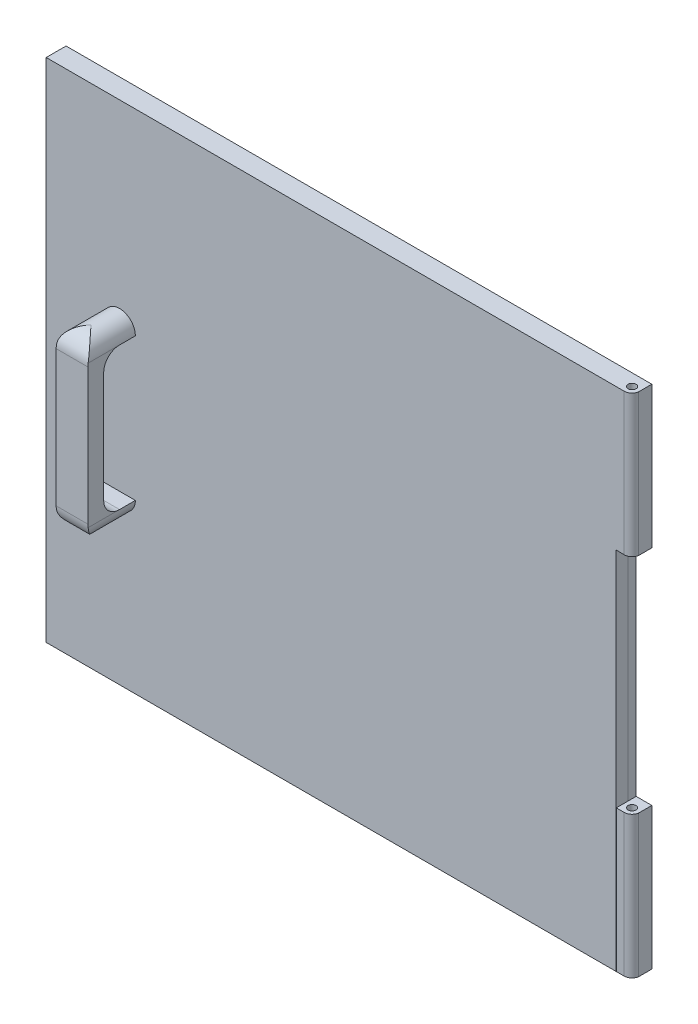
from build123d import *

# Parameters (mm, degrees)
BOSS_EXTRUDE1_DEPTH = 5
BOSS_EXTRUDE2_REACH = 322
SKETCH2_W           = 10
SKETCH2_H           = 15
SKETCH3_W           = 9.887044096
SKETCH3_H           = 15
BOSS_EXTRUDE3_DEPTH = 89.560962
SKETCH4_R           = 2.5
CUT_EXTRUDE1_DEPTH  = 320
SKETCH5_W           = 360
SKETCH5_H           = 7.556477952
BOSS_EXTRUDE4_DEPTH = 320
BOSS_EXTRUDE5_DEPTH = 30
CUT_EXTRUDE2_DEPTH  = 30


with BuildPart() as part:
    # Sketch1 → Boss-Extrude1 (new body)
    with BuildSketch(Plane.XY):
        Polygon((175.89978938, 161.770375321), (-184.213166524, 161.770375321), (-184.213166524, -158.229624679), (175.89978938, -158.229624679), (185.786833476, -158.229624679), (185.786833476, -68.668662794), (175.89978938, -68.668662794), (175.89978938, 72.40143746), (185.786833476, 72.209413435), (185.786833476, 161.770375321), align=None)
    extrude(amount=BOSS_EXTRUDE1_DEPTH)

    # Boss-Extrude2: up to this face of the body (flat: up to its plane)
    boss_extrude2_end = Plane(part.part.faces().sort_by_distance((180.843311428, 72.305425448, 2.5))[0])
    # Sketch2 → Boss-Extrude2 (add, up to the picked face)
    with BuildSketch(Plane(origin=(0, 161.770375321, 0), x_dir=(1, 0, 0), z_dir=(0, 1, 0)), mode=Mode.PRIVATE) as boss_extrude2_sk1:
        with Locations((180.786833476, -7.5)):
            Rectangle(SKETCH2_W, SKETCH2_H)
    boss_extrude2_tool1 = split(extrude(boss_extrude2_sk1.sketch, amount=-BOSS_EXTRUDE2_REACH, mode=Mode.PRIVATE), bisect_by=boss_extrude2_end, keep=Keep.BOTH, mode=Mode.PRIVATE)
    add(boss_extrude2_tool1.solids().sort_by_distance((180.786833, 161.770375, 7.5))[0])

    # Sketch3 → Boss-Extrude3 (add)
    with BuildSketch(Plane.XZ.offset(158.229624679)):
        with Locations((180.843311428, 7.5)):
            Rectangle(SKETCH3_W, SKETCH3_H)
    extrude(amount=-BOSS_EXTRUDE3_DEPTH)

    # Sketch4 → Cut-Extrude1 (cut)
    with BuildSketch(Plane(origin=(0, 161.770375321, 0), x_dir=(1, 0, 0), z_dir=(0, 1, 0))):
        with Locations((180.843311428, -7.5)):
            Circle(SKETCH4_R)
        with BuildLine():
            Line((180.843311428, -12.556477952), (174.586681461, -12.556477952))
            Line((174.586681461, -12.556477952), (174.586681461, -18.742126007))
            Line((174.586681461, -18.742126007), (187.888181218, -19.204340284))
            Line((187.888181218, -19.204340284), (188.294895745, -7.5))
            Line((188.294895745, -7.5), (185.89978938, -7.5))
            ThreePointArc((185.89978938, -7.5), (184.418781277, -11.075469849), (180.843311428, -12.556477952))
        make_face()
    extrude(amount=-CUT_EXTRUDE1_DEPTH, mode=Mode.SUBTRACT)

    # Sketch5 → Boss-Extrude4 (add)
    with BuildSketch(Plane(origin=(0, 161.770375321, 0), x_dir=(1, 0, 0), z_dir=(0, 1, 0))):
        with Locations((-4.213166524, -8.778238976)):
            Rectangle(SKETCH5_W, SKETCH5_H)
    extrude(amount=-BOSS_EXTRUDE4_DEPTH)

    # Sketch6 → Boss-Extrude5 (add)
    with BuildSketch(Plane.XY.offset(12.556477952)):
        with BuildLine():
            Line((-127.887955303, 37.634320881), (-127.887955303, -52.365679119))
            ThreePointArc((-127.887955303, -52.365679119), (-137.887955303, -62.365679119), (-147.887955303, -52.365679119))
            Line((-147.887955303, -52.365679119), (-147.887955303, 37.634320881))
            ThreePointArc((-147.887955303, 37.634320881), (-137.887955303, 47.634320881), (-127.887955303, 37.634320881))
        make_face()
    extrude(amount=BOSS_EXTRUDE5_DEPTH)

    # Sketch7 → Cut-Extrude2 (cut)
    with BuildSketch(Plane.ZY.offset(147.887955303)):
        with BuildLine():
            Line((12.556477952, 47.634320881), (30.556477952, 47.634320881))
            ThreePointArc((30.556477952, 47.634320881), (39.041759326, 44.119602255), (42.556477952, 35.634320881))
            Line((42.556477952, 35.634320881), (42.556477952, -50.365679119))
            ThreePointArc((42.556477952, -50.365679119), (39.041759326, -58.850960494), (30.556477952, -62.365679119))
            Line((30.556477952, -62.365679119), (12.556477952, -62.365679119))
            Line((12.556477952, -62.365679119), (12.556477952, -84.546006254))
            Line((12.556477952, -84.546006254), (75.194935331, -84.546006254))
            Line((75.194935331, -84.546006254), (75.194935331, -40.351574991))
            Line((75.194935331, -40.351574991), (70.864672609, 64.078414926))
            Line((70.864672609, 64.078414926), (12.556477952, 64.078414926))
            Line((12.556477952, 64.078414926), (12.556477952, 47.634320881))
        make_face()
        with BuildLine():
            Line((32.556477952, -7.365679119), (32.556477952, 27.634320881))
            ThreePointArc((32.556477952, 27.634320881), (29.627545764, 34.705388692), (22.556477952, 37.634320881))
            Line((22.556477952, 37.634320881), (12.556477952, 37.634320881))
            Line((12.556477952, 37.634320881), (12.556477952, -52.365679119))
            Line((12.556477952, -52.365679119), (22.556477952, -52.365679119))
            ThreePointArc((22.556477952, -52.365679119), (29.627545764, -49.436746931), (32.556477952, -42.365679119))
            Line((32.556477952, -42.365679119), (32.556477952, -7.365679119))
        make_face()
    extrude(amount=-CUT_EXTRUDE2_DEPTH, mode=Mode.SUBTRACT)


solid = part.part
